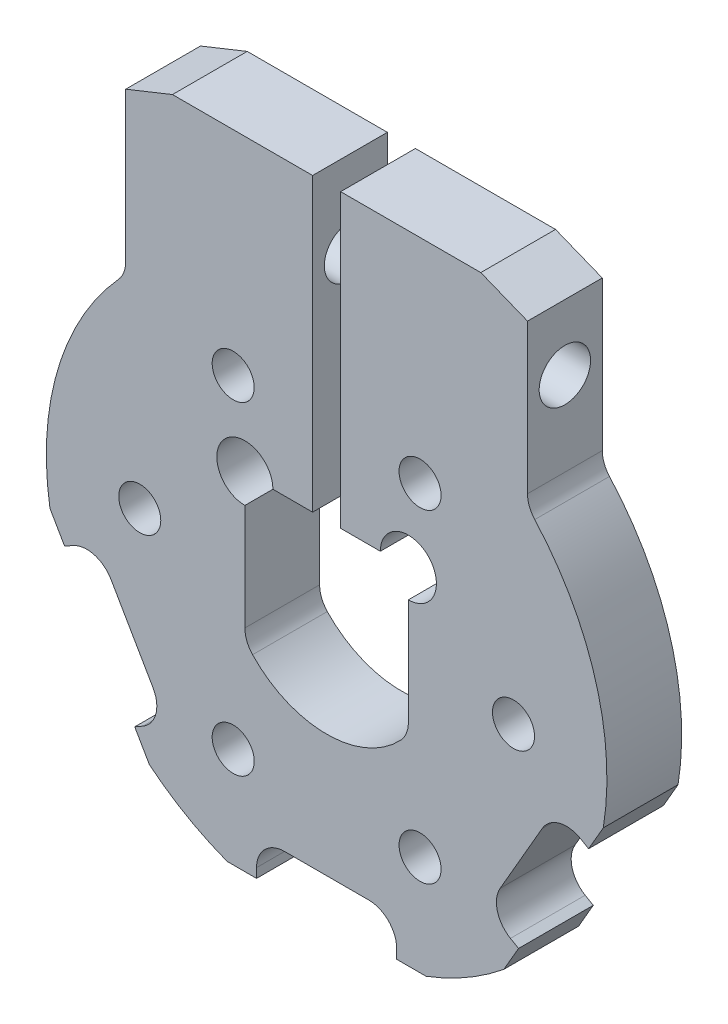
from build123d import *

# Parameters (mm, degrees)
AUFSATZ_LINEAR_AUSTRAGEN1_DEPTH = 8
DURCHGANGSLOCH_F_R_M5_D         = 5.5
DURCHGANGSLOCH_F_R_M4_D         = 4.5


with BuildPart() as part:
    # Skizze1 → Aufsatz-Linear austragen1 (new body)
    with BuildSketch(Plane.XY):
        with BuildLine():
            Line((4.5, -24.047375097), (-4.5, -24.047375097))
            ThreePointArc((-4.5, -24.047375097), (-6.621320344, -24.926054753), (-7.5, -27.047375097))
            Line((-7.5, -27.047375097), (-7.5, -28.047375097))
            Line((-7.5, -28.047375097), (-10.646349149, -28.047375097))
            ThreePointArc((-10.646349149, -28.047375097), (-15, -25.980762114), (-18.966564769, -23.243696368))
            Line((-18.966564769, -23.243696368), (-20.539739343, -20.518878077))
            Line((-20.539739343, -20.518878077), (-19.673713939, -20.018878077))
            ThreePointArc((-19.673713939, -20.018878077), (-18.27593646, -18.197259001), (-18.575637728, -15.920801865))
            Line((-18.575637728, -15.920801865), (-23.075637728, -8.126573231))
            ThreePointArc((-23.075637728, -8.126573231), (-24.897256804, -6.728795752), (-27.173713939, -7.02849702))
            Line((-27.173713939, -7.02849702), (-28.039739343, -7.52849702))
            Line((-28.039739343, -7.52849702), (-29.612913917, -4.803678728))
            ThreePointArc((-29.612913917, -4.803678728), (-28.775894551, 8.482210373), (-22.272727273, 20.097900881))
            ThreePointArc((-22.272727273, 20.097900881), (-21.699837667, 21.031080126), (-21.5, 22.107690969))
            Line((-21.5, 22.107690969), (-21.5, 38.107690969))
            Line((-21.5, 38.107690969), (-16.5, 40.107690969))
            Line((-16.5, 40.107690969), (-1.5, 40.107690969))
            Line((-1.5, 40.107690969), (-1.5, 8.9))
            Line((-1.5, 8.9), (-5.75, 8.9))
            ThreePointArc((-5.75, 8.9), (-10.871320344, 11.021320344), (-8.75, 5.9))
            Line((-8.75, 5.9), (-8.75, -5.459334644))
            ThreePointArc((-8.75, -5.459334644), (-8.536286844, -6.571362352), (-7.925596252, -7.524953425))
            ThreePointArc((-7.925596252, -7.524953425), (0, -10.928860874), (7.925596252, -7.524953425))
            ThreePointArc((7.925596252, -7.524953425), (8.536286844, -6.571362352), (8.75, -5.459334644))
            Line((8.75, -5.459334644), (8.75, 5.9))
            ThreePointArc((8.75, 5.9), (10.871320344, 11.021320344), (5.75, 8.9))
            Line((5.75, 8.9), (1.5, 8.9))
            Line((1.5, 8.9), (1.5, 40.107690969))
            Line((1.5, 40.107690969), (16.5, 40.107690969))
            Line((16.5, 40.107690969), (21.5, 38.107690969))
            Line((21.5, 38.107690969), (21.5, 22.107690969))
            ThreePointArc((21.5, 22.107690969), (21.699837667, 21.031080126), (22.272727273, 20.097900881))
            ThreePointArc((22.272727273, 20.097900881), (28.775894551, 8.482210373), (29.612913917, -4.803678728))
            Line((29.612913917, -4.803678728), (28.039739343, -7.52849702))
            Line((28.039739343, -7.52849702), (27.173713939, -7.02849702))
            ThreePointArc((27.173713939, -7.02849702), (24.897256804, -6.728795752), (23.075637728, -8.126573231))
            Line((23.075637728, -8.126573231), (18.575637728, -15.920801865))
            ThreePointArc((18.575637728, -15.920801865), (18.27593646, -18.197259001), (19.673713939, -20.018878077))
            Line((19.673713939, -20.018878077), (20.539739343, -20.518878077))
            Line((20.539739343, -20.518878077), (18.966564769, -23.243696368))
            ThreePointArc((18.966564769, -23.243696368), (15, -25.980762114), (10.646349149, -28.047375097))
            Line((10.646349149, -28.047375097), (7.5, -28.047375097))
            Line((7.5, -28.047375097), (7.5, -27.047375097))
            ThreePointArc((7.5, -27.047375097), (6.621320344, -24.926054753), (4.5, -24.047375097))
        make_face()
    extrude(amount=AUFSATZ_LINEAR_AUSTRAGEN1_DEPTH)

    # Durchgangsloch für M5 (through all)
    with Locations(Plane(origin=(21.5, 0, 0), x_dir=(0, 0, -1), z_dir=(1, 0, 0))):
        with Locations((-4, 31.107690969)):
            Hole(DURCHGANGSLOCH_F_R_M5_D / 2)

    # Durchgangsloch für M4 (through all)
    with Locations(Plane.XY.offset(8)):
        with Locations((-20, 0), (-10, 17.320508076), (10, 17.320508076), (20, 0), (10, -17.320508076), (-10, -17.320508076)):
            Hole(DURCHGANGSLOCH_F_R_M4_D / 2)


solid = part.part
